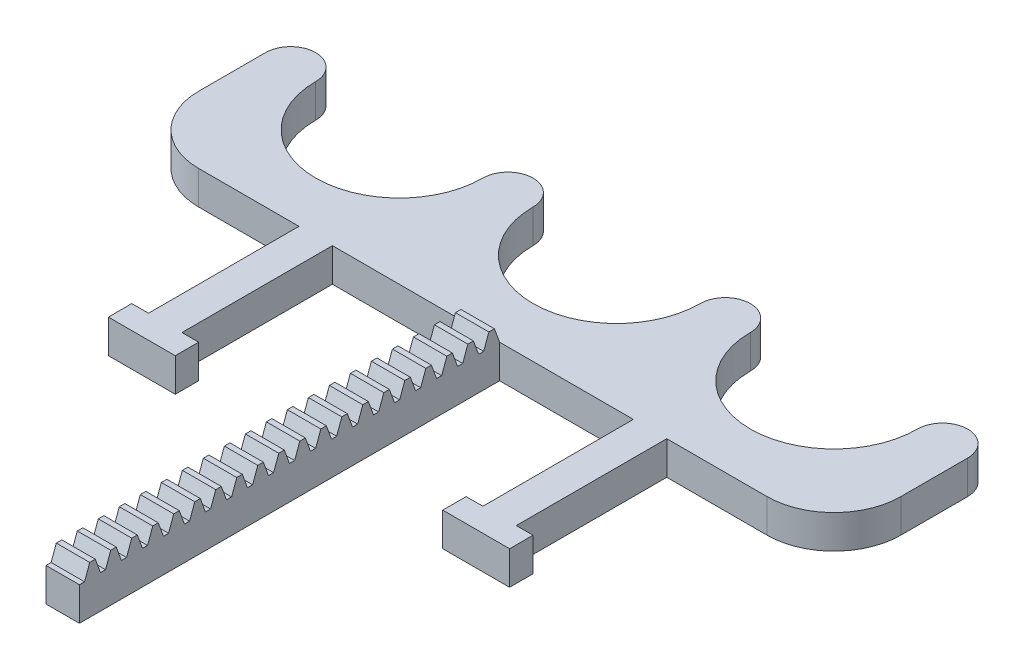
from build123d import *

# Parameters (mm, degrees)
BOSS_EXTRU_1_DEPTH = 10
ESQUISSE2_W        = 10
ESQUISSE2_H        = 45
BOSS_EXTRU_2_DEPTH = 10
CONG_1_R           = 20
BOSS_EXTRU_3_DEPTH = 10


with BuildPart() as part:
    # Esquisse1 → Boss.-Extru.1 (new body)
    with BuildSketch(Plane(origin=(0, 0, 0), x_dir=(1, 0, 0), z_dir=(0, 1, 0))):
        with BuildLine():
            Line((0, 0), (210, 0))
            Line((210, 0), (210, 40))
            ThreePointArc((210, 40), (202.5, 47.5), (195, 40))
            ThreePointArc((195, 40), (170, 15), (145, 40))
            ThreePointArc((145, 40), (137.5, 47.5), (130, 40))
            ThreePointArc((130, 40), (105, 15), (80, 40))
            ThreePointArc((80, 40), (72.5, 47.5), (65, 40))
            ThreePointArc((65, 40), (40, 15), (15, 40))
            ThreePointArc((15, 40), (7.5, 47.5), (0, 40))
            Line((0, 40), (0, 0))
        make_face()
    extrude(amount=BOSS_EXTRU_1_DEPTH)

    # Esquisse2 → Boss.-Extru.2 (add)
    with BuildSketch(Plane(origin=(0, 10, 0), x_dir=(1, 0, 0), z_dir=(0, 1, 0))):
        Polygon((60, -45), (50, -45), (45, -45), (45, -52), (65, -52), (65, -45), align=None)
        with Locations((55, -22.5)):
            Rectangle(ESQUISSE2_W, ESQUISSE2_H)
        with Locations((105, -22.5)):
            Rectangle(ESQUISSE2_W, ESQUISSE2_H)
        with Locations((155, -22.5)):
            Rectangle(ESQUISSE2_W, ESQUISSE2_H)
        Polygon((160, -45), (150, -45), (145, -45), (145, -52), (165, -52), (165, -45), align=None)
    extrude(amount=-BOSS_EXTRU_2_DEPTH)

    # Congé1
    cong_1_edges = [part.edges().sort_by_distance(p)[0] for p in [
        (210, 5, 0),
        (0, 5, 0),
    ]]
    fillet(cong_1_edges, radius=CONG_1_R)

    # Esquisse3 → Boss.-Extru.3 (add)
    with BuildSketch(Plane.ZY.offset(-100)):
        Polygon((3.209033432, 14.25), (4.755906928, 10), (6.283, 10), (7.829873496, 14.25), (9.492033432, 14.25), (11.038906928, 10), (12.566, 10), (14.112873496, 14.25), (15.775033432, 14.25), (17.321906928, 10), (18.849, 10), (20.395873496, 14.25), (22.058033432, 14.25), (23.604906928, 10), (25.132, 10), (26.678873496, 14.25), (28.341033432, 14.25), (29.887906928, 10), (31.415, 10), (32.961873496, 14.25), (34.624033432, 14.25), (36.170906928, 10), (37.698, 10), (39.244873496, 14.25), (40.907033432, 14.25), (42.453906928, 10), (43.981, 10), (45.527873496, 14.25), (47.190033432, 14.25), (48.736906928, 10), (50.264, 10), (51.810873496, 14.25), (53.473033432, 14.25), (55.019906928, 10), (56.547, 10), (58.093873496, 14.25), (59.756033432, 14.25), (61.302906928, 10), (62.83, 10), (64.376873496, 14.25), (66.039033432, 14.25), (67.585906928, 10), (69.113, 10), (70.659873496, 14.25), (72.322033432, 14.25), (73.868906928, 10), (75.396, 10), (76.942873496, 14.25), (78.605033432, 14.25), (80.151906928, 10), (81.679, 10), (83.225873496, 14.25), (84.888033432, 14.25), (86.434906928, 10), (87.962, 10), (89.508873496, 14.25), (91.171033432, 14.25), (92.717906928, 10), (94.245, 10), (95.791873496, 14.25), (97.454033432, 14.25), (99.000906928, 10), (100.528, 10), (102.074873496, 14.25), (103.737033432, 14.25), (105.283906928, 10), (106.811, 10), (108.357873496, 14.25), (110.020033432, 14.25), (111.566906928, 10), (113.094, 10), (114.640873496, 14.25), (116.303033432, 14.25), (117.849906928, 10), (119.377, 10), (120.923873496, 14.25), (122.586033432, 14.25), (124.132906928, 10), (125.66, 10), (125.66, 0), (0, 0), (0, 10), (1.546873496, 14.25), align=None)
    extrude(amount=-BOSS_EXTRU_3_DEPTH)


solid = part.part
